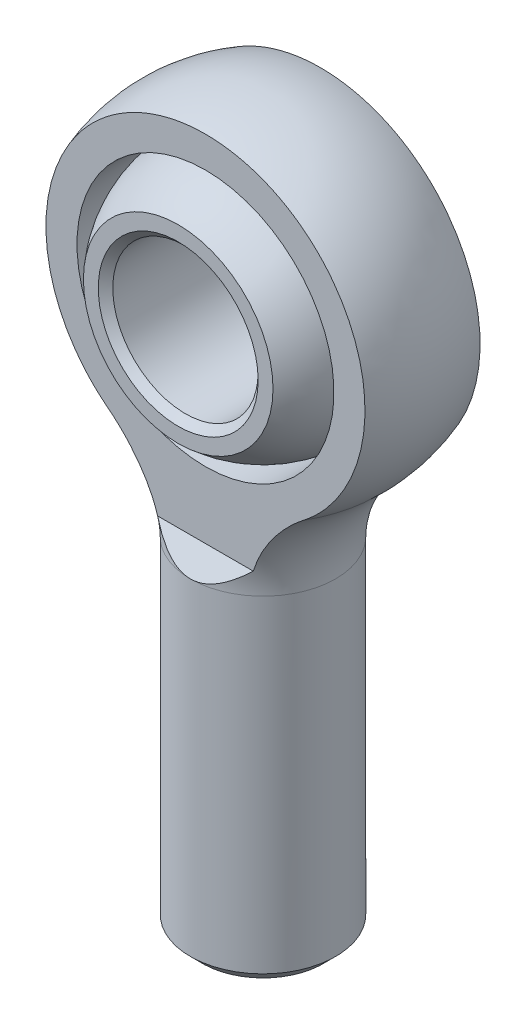
from build123d import *

# Parameters (mm, degrees)
SKETCH1_W               = 9.525
SKETCH1_H               = 44.45
CHAMFER2_SIZE           = 1.5875
CUT_EXTRUDE1_DEPTH      = 60.737268518
CUT_EXTRUDE1_DEPTH_BACK = 60.737268518
CUT_EXTRUDE2_DEPTH      = 57.261143358
CUT_EXTRUDE2_DEPTH_BACK = 57.261143358
SKETCH6_R               = 16.8354375
CUT_EXTRUDE3_DEPTH      = 58.900240514
CUT_EXTRUDE3_DEPTH_BACK = 58.900240514
SKETCH8_W               = 11.1125
SKETCH8_H               = 50.8
CUT_EXTRUDE4_DEPTH      = 58.900240514
CUT_EXTRUDE4_DEPTH_BACK = 58.900240514
SKETCH10_R              = 9.525
CHAMFER1_SIZE           = 0.9525


with BuildPart() as part:
    # Sketch1 → Revolve1 (revolve)
    with BuildSketch(Plane.XY, mode=Mode.PRIVATE) as revolve1_sk:
        with Locations((4.7625, -22.225)):
            Rectangle(SKETCH1_W, SKETCH1_H)
    revolve(revolve1_sk.sketch.rotate(Axis((0, 50.8, 0), (0, -1, 0)), 180), axis=Axis((0, 50.8, 0), (0, -1, 0)))

    # Chamfer2
    chamfer2_edges = [part.edges().sort_by_distance(p)[0] for p in [
        (9.525, -44.45, 0),
    ]]
    chamfer(chamfer2_edges, length=CHAMFER2_SIZE)

    # Sketch4 → Revolve2 (revolve)
    with BuildSketch(Plane.XY):
        with BuildLine():
            Line((9.525, 0), (0, 0))
            Line((0, 0), (0, 50.8))
            ThreePointArc((0, 50.8), (20.743606098, 36.553310038), (14.893041237, 12.078092784))
            ThreePointArc((14.893041237, 12.078092784), (10.927447707, 6.608634352), (9.525, 0))
        make_face()
    revolve(axis=Axis((0, 50.8, 0), (0, 1, 0)))

    # Sketch5 → Cut-Extrude1 (cut, two sides: drawn at the far end of the back side and taken through both)
    with BuildSketch(Plane(origin=(0, 0, 0), x_dir=(0, 0, -1), z_dir=(1, 0, 0)).offset(-CUT_EXTRUDE1_DEPTH_BACK)):
        Polygon((7.540625, 50.8), (22.225, 50.8), (22.225, 0), (9.525, 0), (7.540625, 3.01625), align=None)
        Polygon((-7.540625, 50.8), (-7.540625, 3.01625), (-9.525, 0), (-22.225, 0), (-22.225, 50.8), align=None)
    extrude(amount=CUT_EXTRUDE1_DEPTH + CUT_EXTRUDE1_DEPTH_BACK, mode=Mode.SUBTRACT)

    # Sketch6 → Cut-Extrude2 (cut, two sides: drawn at the far end of the back side and taken through both)
    with BuildSketch(Plane.XY.offset(-CUT_EXTRUDE2_DEPTH_BACK)):
        with Locations(Location((0, 28.575, 0), (0, 0, 270))):
            Circle(SKETCH6_R)
    extrude(amount=CUT_EXTRUDE2_DEPTH + CUT_EXTRUDE2_DEPTH_BACK, mode=Mode.SUBTRACT)


with BuildPart() as body_2:
    # Sketch7 → Revolve3 (revolve)
    with BuildSketch(Plane.XY):
        with BuildLine():
            Line((0, 45.24375), (0, 11.90625))
            ThreePointArc((0, 11.90625), (16.66875, 28.575), (0, 45.24375))
        make_face()
    revolve(axis=Axis((0, 0, 0), (0, 1, 0)))

    # Sketch8 → Cut-Extrude3 (cut, two sides: drawn at the far end of the back side and taken through both)
    with BuildSketch(Plane(origin=(0, 0, 0), x_dir=(0, 0, -1), z_dir=(1, 0, 0)).offset(-CUT_EXTRUDE3_DEPTH_BACK)):
        with Locations((-16.66875, 25.4)):
            Rectangle(SKETCH8_W, SKETCH8_H)
        with Locations((16.66875, 25.4)):
            Rectangle(SKETCH8_W, SKETCH8_H)
    extrude(amount=CUT_EXTRUDE3_DEPTH + CUT_EXTRUDE3_DEPTH_BACK, mode=Mode.SUBTRACT)

    # Sketch10 → Cut-Extrude4 (cut, two sides: drawn at the far end of the back side and taken through both)
    with BuildSketch(Plane.XY.offset(-CUT_EXTRUDE4_DEPTH_BACK)):
        with Locations((0, 28.575)):
            Circle(SKETCH10_R)
    extrude(amount=CUT_EXTRUDE4_DEPTH + CUT_EXTRUDE4_DEPTH_BACK, mode=Mode.SUBTRACT)

    # Chamfer1
    chamfer1_edges = [body_2.edges().sort_by_distance(p)[0] for p in [
        (-9.525, 28.575, -11.1125),
        (-9.525, 28.575, 11.1125),
    ]]
    chamfer(chamfer1_edges, length=CHAMFER1_SIZE)


solid = Compound([part.part, body_2.part])
